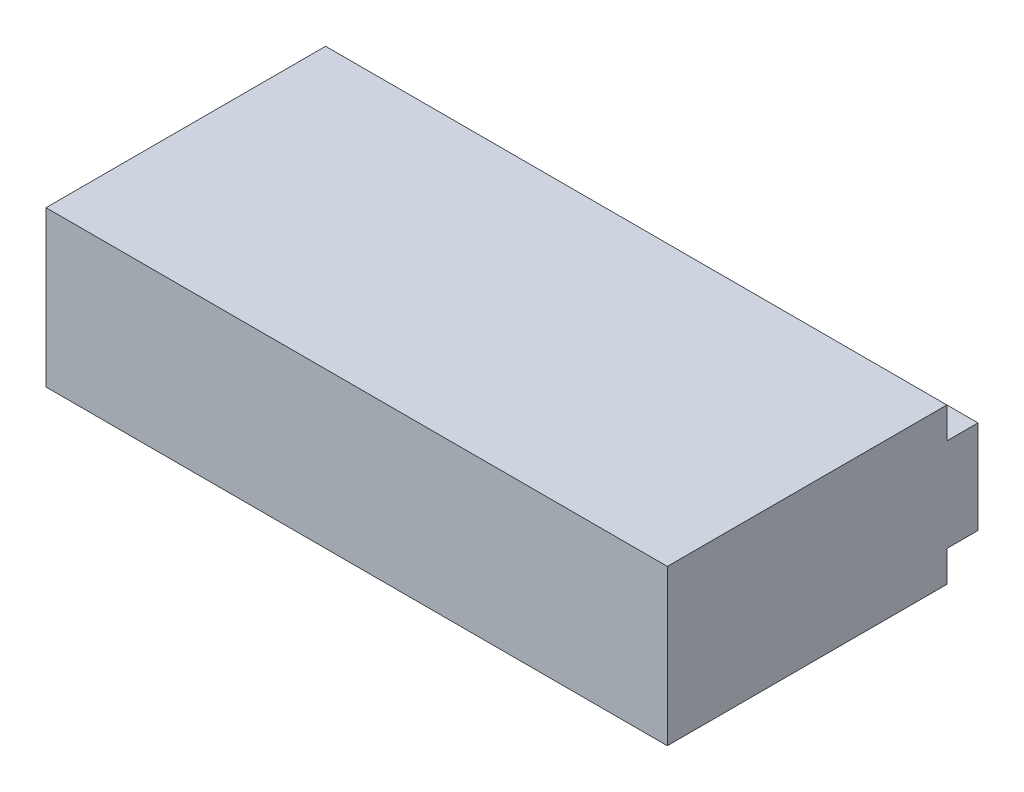
from build123d import *

# Parameters (mm, degrees)
SKICA1_W                 = 10
SKICA1_H                 = 2.5
P_IDAT_VYSUNUT_M1_DEPTH  = 5
SKICA2_W                 = 0.5
SKICA2_H                 = 0.5
ODEBRAT_VYSUNUT_M1_DEPTH = 11
SKICA3_R                 = 0.25
ODEBRAT_VYSUNUT_M2_DEPTH = 1


with BuildPart() as part:
    # Skica1 → Přidat vysunutím1 (new body)
    with BuildSketch(Plane.XY):
        Rectangle(SKICA1_W, SKICA1_H)
    extrude(amount=P_IDAT_VYSUNUT_M1_DEPTH)

    # Skica2 → Odebrat vysunutím1 (cut, through all)
    with BuildSketch(Plane(origin=(5, 0, 0), x_dir=(0, 0, -1), z_dir=(1, 0, 0))):
        with Locations((-0.25, 1)):
            Rectangle(SKICA2_W, SKICA2_H)
        with Locations((-0.25, -1)):
            Rectangle(SKICA2_W, SKICA2_H)
    extrude(amount=-ODEBRAT_VYSUNUT_M1_DEPTH, mode=Mode.SUBTRACT)

    # Skica3 → Odebrat vysunutím2 (cut)
    with BuildSketch(Plane(origin=(0, 0, 0), x_dir=(-1, 0, 0), z_dir=(0, 0, -1))):
        Circle(SKICA3_R)
        with Locations((-2.54, 0)):
            Circle(SKICA3_R)
        with Locations((2.54, 0)):
            Circle(SKICA3_R)
    extrude(amount=-ODEBRAT_VYSUNUT_M2_DEPTH, mode=Mode.SUBTRACT)


solid = part.part
